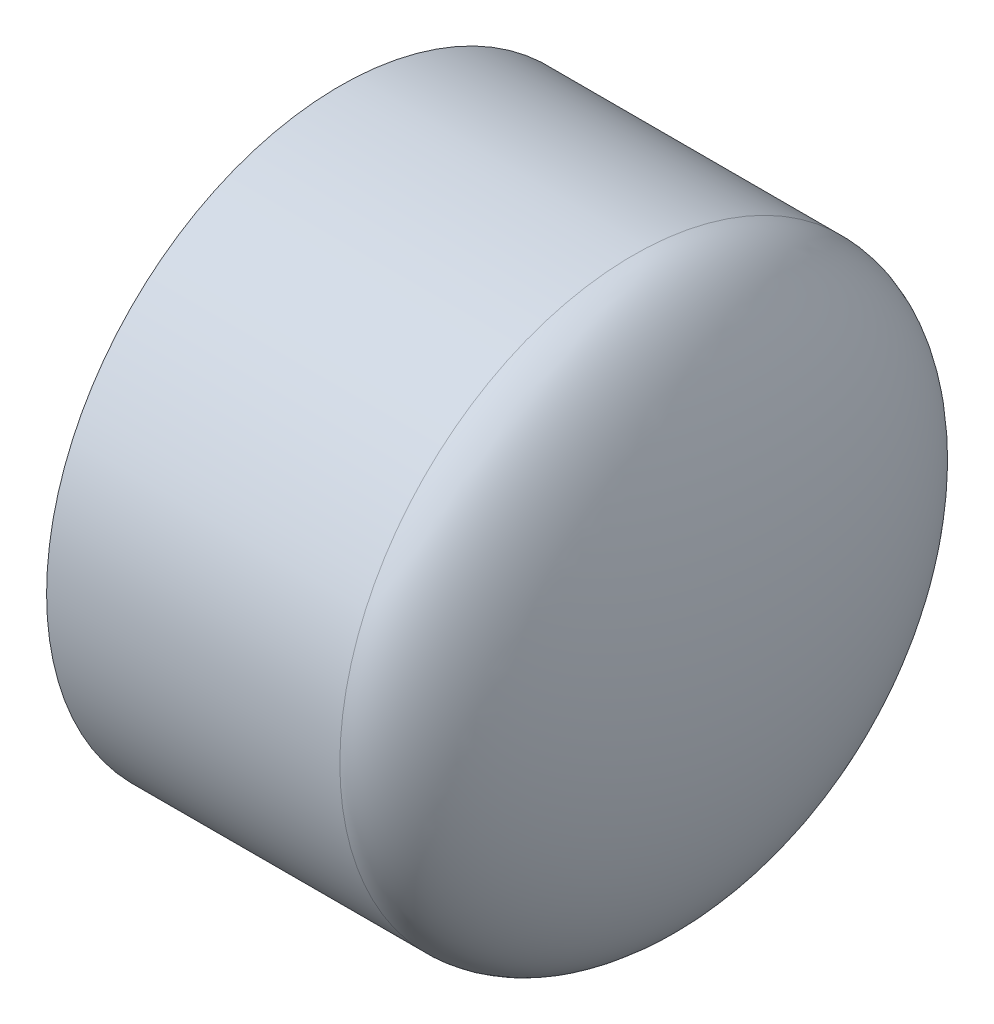
from build123d import *


with BuildPart() as part:
    # Sketch1 → Revolve1 (revolve)
    with BuildSketch(Plane.XY):
        with BuildLine():
            Line((-52.832, -38.1), (-14.732, -38.1))
            add(Edge.make_bspline(
                [(-14.732, -38.1), (0, -38.1), (0, 0)],
                knots=[3.141592654, 3.141592654, 3.141592654, 4.71238898, 4.71238898, 4.71238898], degree=2, weights=[1, 0.707106781, 1]))
            Line((0, 0), (-8.0137, 0))
            add(Edge.make_bspline(
                [(-14.732, -30.0863), (-8.0137, -30.0863), (-8.0137, 0)],
                knots=[0, 0, 0, 1.570796327, 1.570796327, 1.570796327], degree=2, weights=[1, 0.707106781, 1]))
            Line((-14.732, -30.0863), (-52.832, -30.3149))
            Line((-52.832, -30.3149), (-52.832, -38.1))
        make_face()
    revolve(axis=Axis((-52.832, 0, 0), (1, 0, 0)))


solid = part.part
